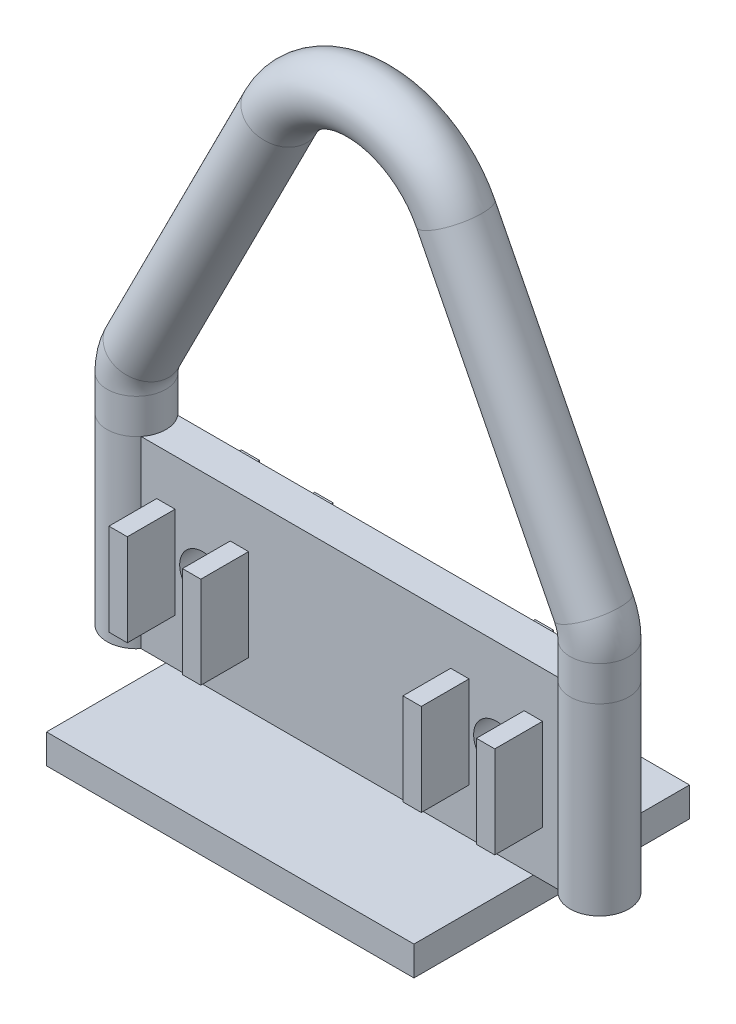
from build123d import *

# Parameters (mm, degrees)
SWEEP1_PROFILE_R        = 16
SKETCH8_W               = 220
SKETCH8_H               = 100
BOSS_EXTRUDE1_DEPTH     = 10
BOSS_EXTRUDE3_START     = -223.510004
SKETCH12_W              = 20
SKETCH12_H              = 100
BOSS_EXTRUDE3_DEPTH     = 227.020008
SKETCH10_R              = 12.5
CUT_EXTRUDE1_DEPTH      = 17.0000001
CUT_EXTRUDE1_DEPTH_BACK = 17.0000001
SKETCH11_W              = 10
SKETCH11_H              = 50
BOSS_EXTRUDE2_DEPTH     = 36
SKETCH15_W              = 150
SKETCH15_H              = 16
BOSS_EXTRUDE4_DEPTH     = 100


with BuildPart() as part:
    # Sweep1: sweep along a path in Sketch1
    with BuildLine(Plane.XY) as sweep1_path:
        Line((-126, -59.5), (-126, 40.5))
        Line((-126, 40.5), (-126, 59.5))
        ThreePointArc((-126, 59.5), (-125.179239367, 66.4693608), (-122.761867336, 73.057376467))
        Line((-122.761867336, 73.057376467), (-47.725330083, 221.177321367))
        ThreePointArc((-47.725330083, 221.177321367), (0, 250.5), (47.725330083, 221.177321367))
        Line((47.725330083, 221.177321367), (122.761867336, 73.057376467))
        ThreePointArc((122.761867336, 73.057376467), (125.179239367, 66.4693608), (126, 59.5))
        Line((126, 59.5), (126, 40.5))
        Line((126, 40.5), (126, -59.5))
    # Sweep1 profile (on start of the path) → Sweep1 (sweep)
    with BuildSketch(Plane(origin=(-126, -59.5, 0), x_dir=(0, 0, 1), z_dir=(0, 1, 0))):
        Circle(SWEEP1_PROFILE_R)
    sweep(path=sweep1_path.line)



with BuildPart() as body_2:
    # Sketch8 → Boss-Extrude1 (new body, symmetric)
    with BuildSketch(Plane.XY):
        with Locations((0, -9.5)):
            Rectangle(SKETCH8_W, SKETCH8_H)
    extrude(amount=BOSS_EXTRUDE1_DEPTH, both=True)


with BuildPart() as part_1:
    add(part.part)

    add(body_2.part)  # Boss-Extrude3 merges body 2
    # Sketch12 → Boss-Extrude3 (add)
    with BuildSketch(Plane.ZY.offset(110).offset(BOSS_EXTRUDE3_START)):
        with Locations((0, -9.5)):
            Rectangle(SKETCH12_W, SKETCH12_H)
    extrude(amount=BOSS_EXTRUDE3_DEPTH)

    # Sketch10 → Cut-Extrude1 (cut, two sides)
    with BuildSketch(Plane.XY) as cut_extrude1_sk:
        with Locations((80, -9.5)):
            Circle(SKETCH10_R)
        with Locations((-80, -9.5)):
            Circle(SKETCH10_R)
    extrude(amount=CUT_EXTRUDE1_DEPTH, mode=Mode.SUBTRACT)
    extrude(cut_extrude1_sk.sketch, amount=-CUT_EXTRUDE1_DEPTH_BACK, mode=Mode.SUBTRACT)

    # Sketch11 → Boss-Extrude2 (add, symmetric)
    with BuildSketch(Plane.XY):
        with Locations((-100, -9.5)):
            Rectangle(SKETCH11_W, SKETCH11_H)
        with Locations((-60, -9.5)):
            Rectangle(SKETCH11_W, SKETCH11_H)
        with Locations((60, -9.5)):
            Rectangle(SKETCH11_W, SKETCH11_H)
        with Locations((100, -9.5)):
            Rectangle(SKETCH11_W, SKETCH11_H)
    extrude(amount=BOSS_EXTRUDE2_DEPTH, both=True)

    # Sketch15 → Boss-Extrude4 (add, symmetric)
    with BuildSketch(Plane(origin=(0, 0, 0), x_dir=(0, 0, -1), z_dir=(1, 0, 0))):
        with Locations((0, -67.5)):
            Rectangle(SKETCH15_W, SKETCH15_H)
    extrude(amount=BOSS_EXTRUDE4_DEPTH, both=True)


solid = part_1.part
